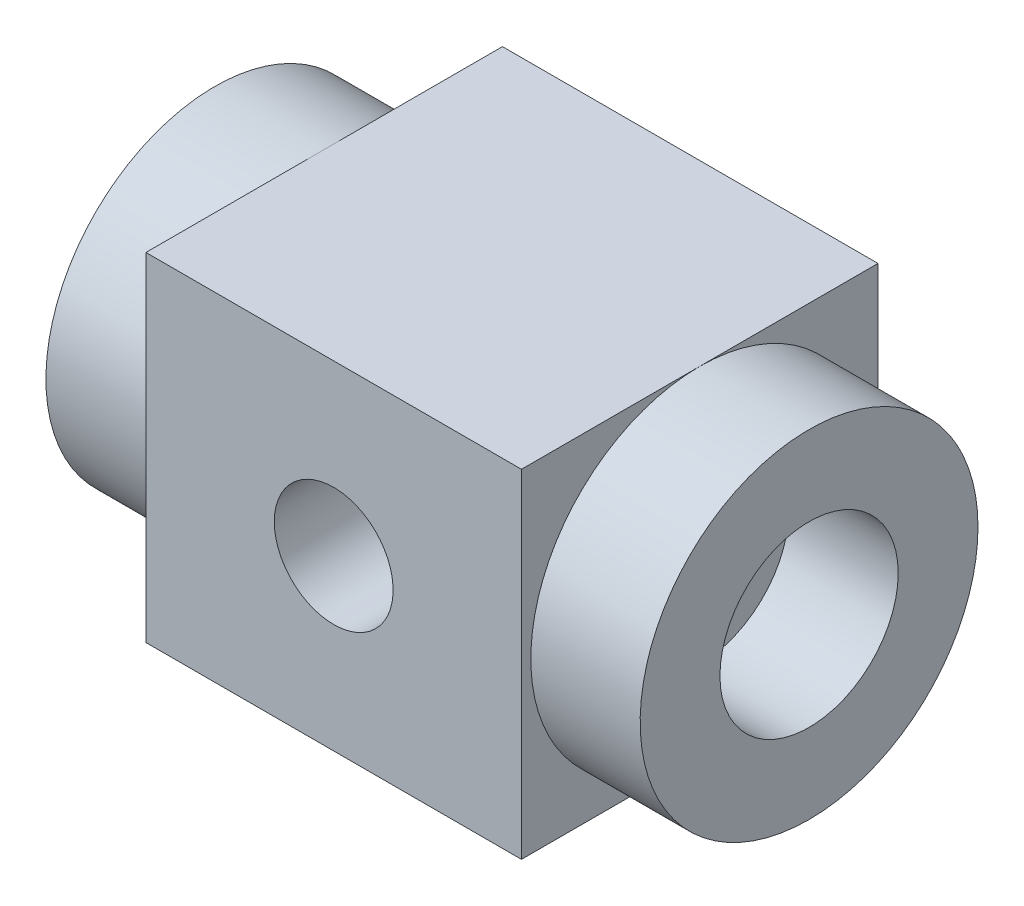
from build123d import *

# Parameters (mm, degrees)
SKETCH1_W           = 31.6
SKETCH1_H           = 28.428065026
BOSS_EXTRUDE1_DEPTH = 30
SKETCH2_R           = 14.214032513
BOSS_EXTRUDE2_DEPTH = 25
SKETCH3_R           = 7.5
CUT_EXTRUDE1_DEPTH  = 75
SKETCH4_R           = 5
CUT_EXTRUDE2_DEPTH  = 75
BOSS_EXTRUDE3_REACH = 30.428
SKETCH5_W           = 4.702962509
SKETCH5_H           = 30
SKETCH5_W_2         = 4.693068718


with BuildPart() as part:
    # Sketch1 → Boss-Extrude1 (new body)
    with BuildSketch(Plane.XY):
        Rectangle(SKETCH1_W, SKETCH1_H)
    extrude(amount=BOSS_EXTRUDE1_DEPTH)

    # Sketch2 → Boss-Extrude2 (add, symmetric)
    with BuildSketch(Plane(origin=(0, 0, 0), x_dir=(0, 0, -1), z_dir=(1, 0, 0))):
        with Locations((-15, 0)):
            Circle(SKETCH2_R)
    extrude(amount=BOSS_EXTRUDE2_DEPTH, both=True)

    # Sketch3 → Cut-Extrude1 (cut)
    with BuildSketch(Plane(origin=(25, 0, 0), x_dir=(0, 0, -1), z_dir=(1, 0, 0))):
        with Locations((-15, 0)):
            Circle(SKETCH3_R)
    extrude(amount=-CUT_EXTRUDE1_DEPTH, mode=Mode.SUBTRACT)

    # Sketch4 → Cut-Extrude2 (cut)
    with BuildSketch(Plane(origin=(0, 0, 0), x_dir=(-1, 0, 0), z_dir=(0, 0, -1))):
        Circle(SKETCH4_R)
    extrude(amount=-CUT_EXTRUDE2_DEPTH, mode=Mode.SUBTRACT)

    # Sketch5 → Boss-Extrude3 (add, up to next)
    with BuildSketch(Plane(origin=(0, 14.214032513, 0), x_dir=(1, 0, 0), z_dir=(0, 1, 0)), mode=Mode.PRIVATE) as boss_extrude3_sk1:
        with Locations((-13.448518745, -15)):
            Rectangle(SKETCH5_W, SKETCH5_H)
    boss_extrude3_tool1 = extrude(boss_extrude3_sk1.sketch, amount=-BOSS_EXTRUDE3_REACH, mode=Mode.PRIVATE) - part.part
    add(boss_extrude3_tool1.solids().sort_by_distance((-13.448519, 14.214033, 15))[0])
    # Sketch5 → Boss-Extrude3 (add, up to next)
    with BuildSketch(Plane(origin=(0, 14.214032513, 0), x_dir=(1, 0, 0), z_dir=(0, 1, 0)), mode=Mode.PRIVATE) as boss_extrude3_sk2:
        with Locations((13.453465641, -15)):
            Rectangle(SKETCH5_W_2, SKETCH5_H)
    boss_extrude3_tool2 = extrude(boss_extrude3_sk2.sketch, amount=-BOSS_EXTRUDE3_REACH, mode=Mode.PRIVATE) - part.part
    add(boss_extrude3_tool2.solids().sort_by_distance((13.453466, 14.214033, 15))[0])


solid = part.part
